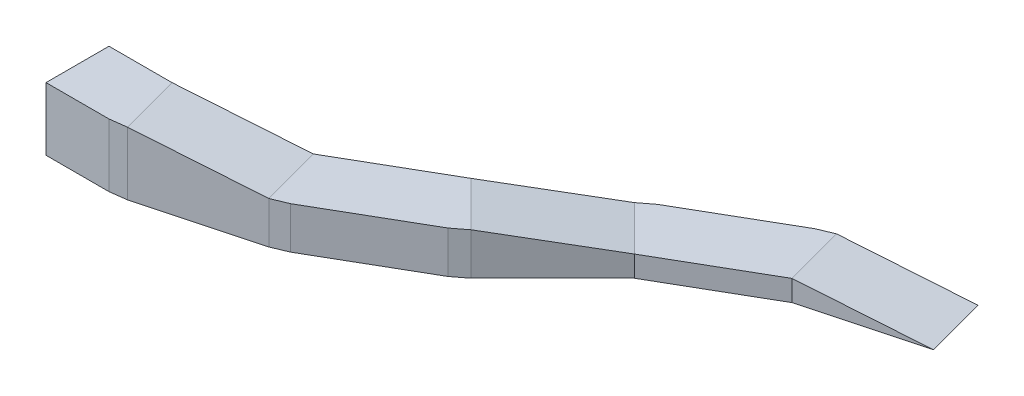
from build123d import *

# Parameters (mm, degrees)
BOSS_EXTRUDE1_DEPTH = 600
CUT_EXTRUDE1_DEPTH  = 600
CUT_EXTRUDE2_DEPTH  = 600
CUT_EXTRUDE3_DEPTH  = 400
CUT_EXTRUDE4_DEPTH  = 600
CUT_EXTRUDE5_DEPTH  = 200
CUT_EXTRUDE6_DEPTH  = 6000
SKETCH16_W          = 2532.923378498
SKETCH16_H          = 1485.911209515
CUT_EXTRUDE7_DEPTH  = 1000


with BuildPart() as part:
    # Sketch1 → Boss-Extrude1 (new body)
    with BuildSketch(Plane(origin=(0, 0, 0), x_dir=(1, 0, 0), z_dir=(0, 1, 0))):
        Polygon((0, 0), (-1000, 0), (-2062.518408918, -284.700949613), (-3015.146353081, -834.700949613), (-3792.963812386, -1612.518408918), (-3917.227881098, -1707.869582477), (-4869.855825261, -2257.869582477), (-5014.564398199, -2317.809835979), (-6077.082807117, -2602.510785592), (-6232.374234179, -2622.955289819), (-7232.374234179, -2622.955289819), (-7232.374234179, -2022.955289819), (-6232.374234179, -2022.955289819), (-5169.855825261, -1738.254340206), (-4217.227881098, -1188.254340206), (-3439.410421793, -410.436880901), (-3315.146353081, -315.085707342), (-2362.518408918, 234.914292658), (-2217.809835979, 294.854546161), (-1155.291427062, 579.555495773), (-1000, 600), (0, 600), align=None)
    extrude(amount=-BOSS_EXTRUDE1_DEPTH)

    # Sketch9 → Cut-Extrude1 (cut)
    with BuildSketch(Plane(origin=(0, 0, 0), x_dir=(1, 0, 0), z_dir=(0, 1, 0))):
        Polygon((-1000, 0), (0, 0), (0, 600), (-1000, 600), (-1155.291427062, 579.555495773), align=None)
    extrude(amount=-CUT_EXTRUDE1_DEPTH, mode=Mode.SUBTRACT)

    # Sketch10 → Cut-Extrude2 (cut)
    with BuildSketch(Plane(origin=(-66.987298108, 0, -250), x_dir=(0.965925826, 0, -0.258819045), z_dir=(0.258819045, 0, 0.965925826))):
        Polygon((-2065.925826289, -400), (-965.925826289, -600), (-965.925826289, 0), (-2065.925826289, 0), align=None)
    extrude(amount=-CUT_EXTRUDE2_DEPTH, mode=Mode.SUBTRACT)

    # Sketch11 → Cut-Extrude3 (cut)
    with BuildSketch(Plane(origin=(0, 0, 0), x_dir=(1, 0, 0), z_dir=(0, 1, 0))):
        Polygon((-2062.518408918, -284.700949613), (-3015.146353081, -834.700949613), (-3439.410421793, -410.436880901), (-3315.146353081, -315.085707342), (-2362.518408918, 234.914292658), (-2217.809835979, 294.854546161), align=None)
    extrude(amount=-CUT_EXTRUDE3_DEPTH, mode=Mode.SUBTRACT)

    # Sketch12 → Cut-Extrude4 (cut)
    with BuildSketch(Plane(origin=(-1090.222701734, 0, -1090.222701734), x_dir=(0.707106781, 0, -0.707106781), z_dir=(0.707106781, 0, 0.707106781))):
        Polygon((-3822.253134267, -200), (-3822.253134267, 0), (-2722.253134267, 0), (-2722.253134267, -400), align=None)
    extrude(amount=-CUT_EXTRUDE4_DEPTH, mode=Mode.SUBTRACT)

    # Sketch13 → Cut-Extrude5 (cut)
    with BuildSketch(Plane(origin=(0, 0, 0), x_dir=(1, 0, 0), z_dir=(0, 1, 0))):
        Polygon((-4217.227881098, -1188.254340206), (-3792.963812386, -1612.518408918), (-3917.227881098, -1707.869582477), (-4869.855825261, -2257.869582477), (-5014.564398199, -2317.809835979), (-5169.855825261, -1738.254340206), align=None)
    extrude(amount=-CUT_EXTRUDE5_DEPTH, mode=Mode.SUBTRACT)

    # Sketch14 → Cut-Extrude6 (cut)
    with BuildSketch(Plane(origin=(243.540338772, 0, 908.90491799), x_dir=(0.965925826, 0, -0.258819045), z_dir=(0.258819045, 0, 0.965925826))):
        Polygon((-5443.590588288, -200), (-6543.590588288, 0), (-5443.590588288, 0), align=None)
    extrude(amount=-CUT_EXTRUDE6_DEPTH, mode=Mode.SUBTRACT)

    # Sketch16 → Cut-Extrude7 (cut)
    with BuildSketch(Plane(origin=(-6832.374234179, 0, 0), x_dir=(0, 0, -1), z_dir=(1, 0, 0))):
        with Locations((-1903.922097594, -233.533191628)):
            Rectangle(SKETCH16_W, SKETCH16_H)
    extrude(amount=-CUT_EXTRUDE7_DEPTH, mode=Mode.SUBTRACT)


solid = part.part
